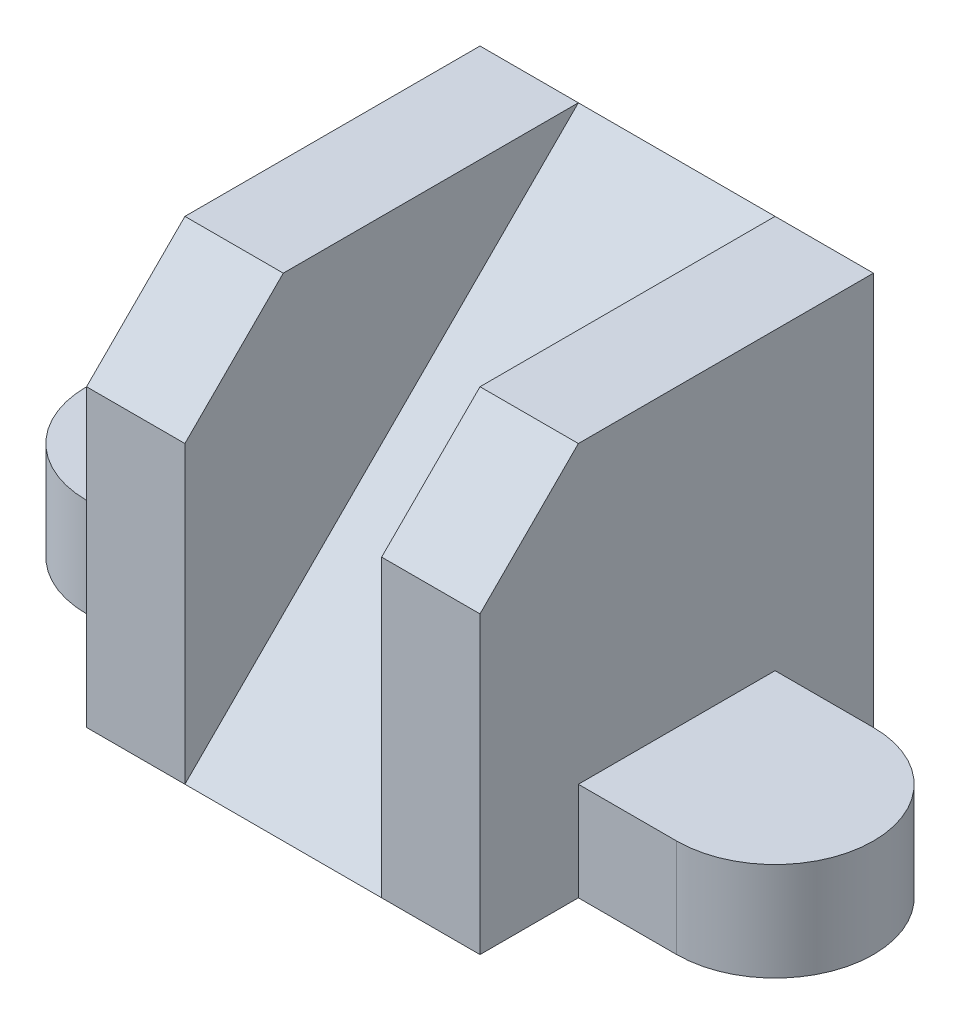
from build123d import *

# Parameters (mm, degrees)
SKETCH1_W           = 7
SKETCH1_H           = 28
BOSS_EXTRUDE1_DEPTH = 28
BOSS_EXTRUDE2_DEPTH = 7
CHAMFER1_SIZE       = 7
BOSS_EXTRUDE3_DEPTH = 7


with BuildPart() as part:
    # Sketch1 → Boss-Extrude1 (new body)
    with BuildSketch(Plane(origin=(0, 0, 0), x_dir=(1, 0, 0), z_dir=(0, 1, 0))):
        with Locations((3.5, 14)):
            Rectangle(SKETCH1_W, SKETCH1_H)
    extrude(amount=BOSS_EXTRUDE1_DEPTH)

    # Sketch1_3 → Boss-Extrude2 (add)
    with BuildSketch(Plane(origin=(0, 0, 0), x_dir=(1, 0, 0), z_dir=(0, 1, 0))):
        with BuildLine():
            Line((7, 21), (7, 7))
            Line((7, 7), (14, 7))
            ThreePointArc((14, 7), (21, 14), (14, 21))
            Line((14, 21), (7, 21))
        make_face()
    extrude(amount=BOSS_EXTRUDE2_DEPTH)

    # Chamfer1
    chamfer1_edges = [part.edges().sort_by_distance(p)[0] for p in [
        (3.5, 28, 0),
    ]]
    chamfer(chamfer1_edges, length=CHAMFER1_SIZE)

    # Sketch2 → Boss-Extrude3 (add)
    with BuildSketch(Plane.ZY):
        Polygon((-28, 28), (0, 0), (-28, 0), align=None)
    extrude(amount=BOSS_EXTRUDE3_DEPTH)

    # Mirror1: part across plane


with BuildPart() as part_1:
    add(part.part)
    add(part.part.mirror(Plane(origin=(-7, 0, 0), x_dir=(0, 0, 1), z_dir=(1, 0, 0))))


solid = part_1.part
